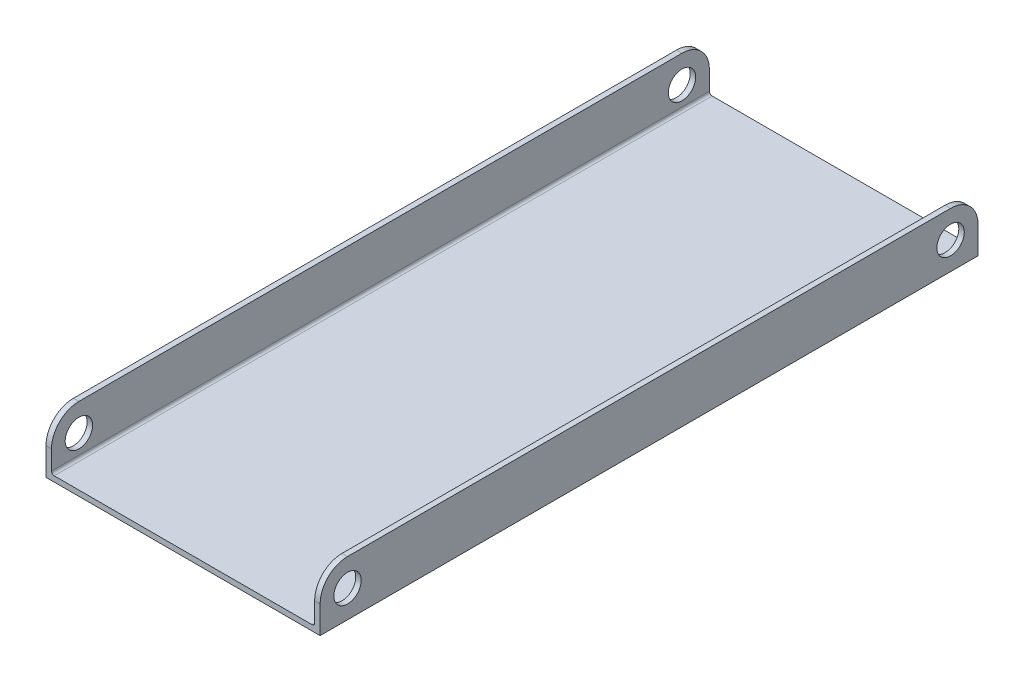
from build123d import *

# Parameters (mm, degrees)
BOSS_EXTRUDE1_DEPTH = 152.4
SKETCH2_R           = 3.175
CUT_EXTRUDE1_DEPTH  = 64.5
FILLET1_R           = 6.35
FILLET2_R           = 0.635


with BuildPart() as part:
    # Sketch1 → Boss-Extrude1 (new body)
    with BuildSketch(Plane.XY):
        Polygon((-31.75, 6.35), (-31.75, -6.35), (31.75, -6.35), (31.75, 6.35), (30.48, 6.35), (30.48, -5.08), (-30.48, -5.08), (-30.48, 6.35), align=None)
    extrude(amount=BOSS_EXTRUDE1_DEPTH)

    # Sketch2 → Cut-Extrude1 (cut, through all)
    with BuildSketch(Plane(origin=(31.75, 0, 0), x_dir=(0, 0, -1), z_dir=(1, 0, 0))):
        with Locations((-146.05, 0)):
            Circle(SKETCH2_R)
        with Locations((-6.35, 0)):
            Circle(SKETCH2_R)
    extrude(amount=-CUT_EXTRUDE1_DEPTH, mode=Mode.SUBTRACT)

    # Fillet1
    fillet1_edges = [part.edges().sort_by_distance(p)[0] for p in [
        (-31.115, 6.35, 0),
        (31.115, 6.35, 0),
        (-31.115, 6.35, 152.4),
        (31.115, 6.35, 152.4),
    ]]
    fillet(fillet1_edges, radius=FILLET1_R)

    # Fillet2
    fillet2_edges = [part.edges().sort_by_distance(p)[0] for p in [
        (-30.48, -5.08, 76.2),
        (30.48, -5.08, 76.2),
    ]]
    fillet(fillet2_edges, radius=FILLET2_R)


solid = part.part
